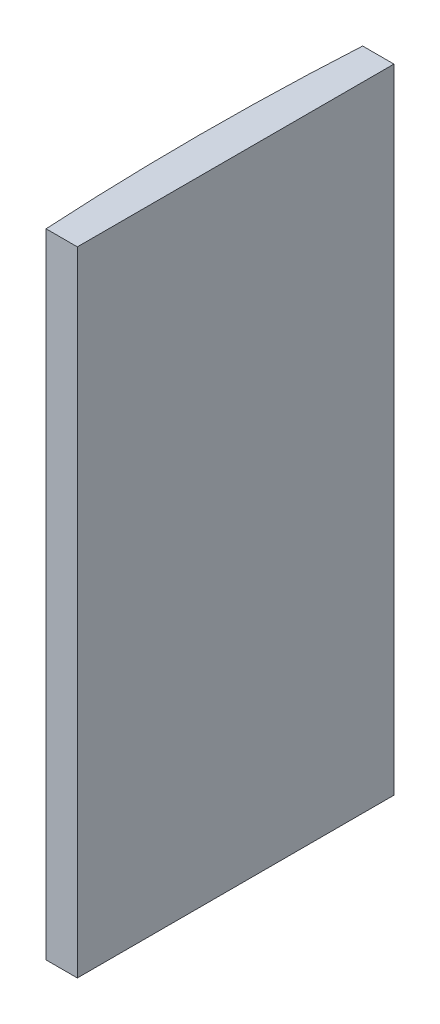
from build123d import *

# Parameters (mm, degrees)
EXTRUDE_1_DEPTH = 60


with BuildPart() as part:
    # 草图1 → 凸台-拉伸1 (new body)
    with BuildSketch(Plane(origin=(0, 0, 0), x_dir=(1, 0, 0), z_dir=(0, 1, 0))):
        with BuildLine():
            Line((-253.709225605, 15), (-250.744795665, 15))
            Line((-250.744795665, 15), (-250.744795665, -15))
            Line((-250.744795665, -15), (-253.709225605, -15))
            ThreePointArc((-253.709225605, -15), (-254.144795665, 0), (-253.709225605, 15))
        make_face()
    extrude(amount=EXTRUDE_1_DEPTH)


solid = part.part
